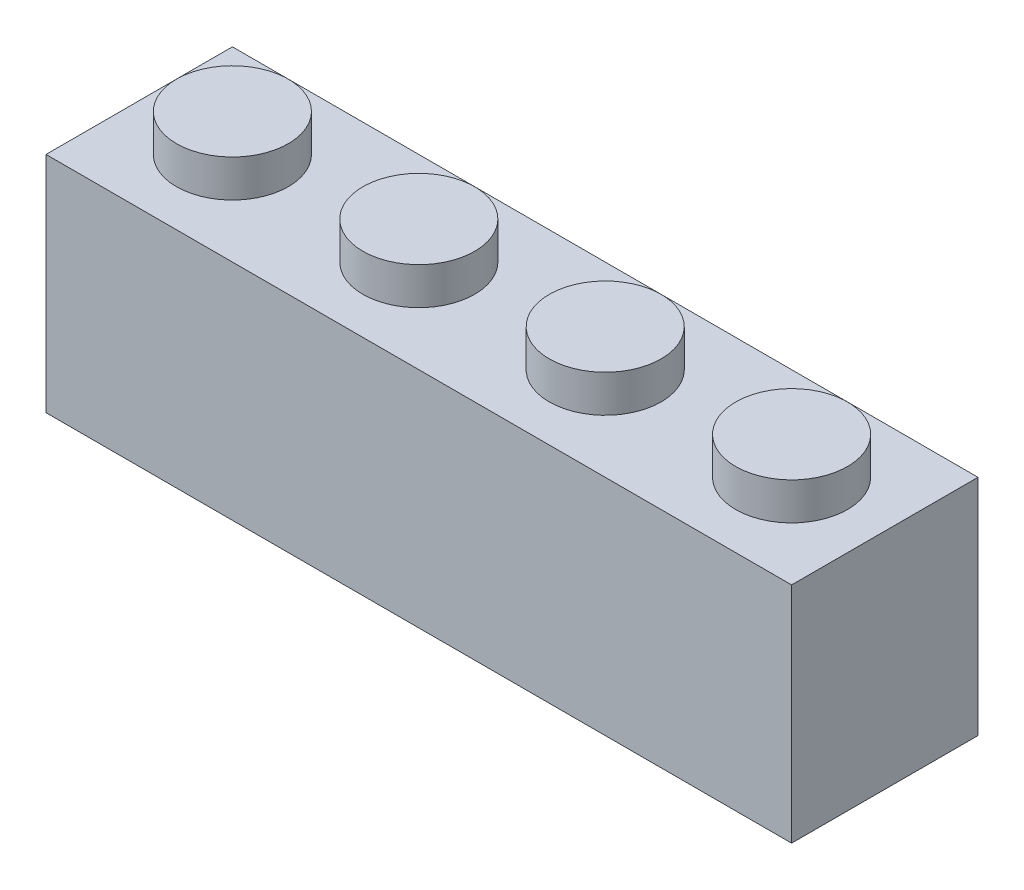
from build123d import *

# Parameters (mm, degrees)
SKETCH1_R             = 1.5
BOSS_EXTRUDE1_DEPTH   = 2
BOSS_EXTRUDE1_2_DEPTH = 2
BOSS_EXTRUDE1_3_DEPTH = 2
BOSS_EXTRUDE1_4_DEPTH = 2
SKETCH1_3_W           = 20
SKETCH1_3_H           = 5
BOSS_EXTRUDE2_DEPTH   = 1
SKETCH1_4_R           = 0.75
CUT_EXTRUDE1_DEPTH    = 1
SKETCH1_6_W           = 20
SKETCH1_6_H           = 5
SKETCH1_6_W_2         = 18
SKETCH1_6_H_2         = 3
SKETCH1_6_R           = 1
BOSS_EXTRUDE4_DEPTH   = 5


with BuildPart() as part:
    # Sketch1 → Boss-Extrude1 (new body)
    with BuildSketch(Plane(origin=(0, 0, 0), x_dir=(1, 0, 0), z_dir=(0, 1, 0))):
        with Locations((-7.5, 0)):
            Circle(SKETCH1_R)
    extrude(amount=BOSS_EXTRUDE1_DEPTH)



with BuildPart() as body_2:
    # Sketch1 → Boss-Extrude1 2 (new body)
    with BuildSketch(Plane(origin=(0, 0, 0), x_dir=(1, 0, 0), z_dir=(0, 1, 0))):
        with Locations((-2.5, 0)):
            Circle(SKETCH1_R)
    extrude(amount=BOSS_EXTRUDE1_2_DEPTH)


with BuildPart() as body_3:
    # Sketch1 → Boss-Extrude1 3 (new body)
    with BuildSketch(Plane(origin=(0, 0, 0), x_dir=(1, 0, 0), z_dir=(0, 1, 0))):
        with Locations((2.5, 0)):
            Circle(SKETCH1_R)
    extrude(amount=BOSS_EXTRUDE1_3_DEPTH)


with BuildPart() as body_4:
    # Sketch1 → Boss-Extrude1 4 (new body)
    with BuildSketch(Plane(origin=(0, 0, 0), x_dir=(1, 0, 0), z_dir=(0, 1, 0))):
        with Locations((7.5, 0)):
            Circle(SKETCH1_R)
    extrude(amount=BOSS_EXTRUDE1_4_DEPTH)


with BuildPart() as part_1:
    add(part.part)

    add(body_2.part)  # Boss-Extrude2 merges body 2

    add(body_3.part)  # Boss-Extrude2 merges body 3

    add(body_4.part)  # Boss-Extrude2 merges body 4
    # Sketch1_3 → Boss-Extrude2 (add)
    with BuildSketch(Plane(origin=(0, 0, 0), x_dir=(1, 0, 0), z_dir=(0, 1, 0))):
        Rectangle(SKETCH1_3_W, SKETCH1_3_H)
    extrude(amount=BOSS_EXTRUDE2_DEPTH)

    # Sketch1_4 → Cut-Extrude1 (cut)
    with BuildSketch(Plane(origin=(0, 0, 0), x_dir=(1, 0, 0), z_dir=(0, 1, 0))):
        with Locations((-7.5, 0)):
            Circle(SKETCH1_4_R)
        with Locations((-2.5, 0)):
            Circle(SKETCH1_4_R)
        with Locations((2.5, 0)):
            Circle(SKETCH1_4_R)
        with Locations((7.5, 0)):
            Circle(SKETCH1_4_R)
    extrude(amount=CUT_EXTRUDE1_DEPTH, mode=Mode.SUBTRACT)

    # Sketch1_6 → Boss-Extrude4 (add)
    # profile 1 of 4: a face of its own
    with BuildSketch(Plane(origin=(0, 0, 0), x_dir=(1, 0, 0), z_dir=(0, 1, 0))):
        Rectangle(SKETCH1_6_W, SKETCH1_6_H)
        Rectangle(SKETCH1_6_W_2, SKETCH1_6_H_2, mode=Mode.SUBTRACT)
    # profile 2 of 4: a face of its own
    with BuildSketch(Plane(origin=(0, 0, 0), x_dir=(1, 0, 0), z_dir=(0, 1, 0))):
        with Locations((5, 0)):
            Circle(SKETCH1_6_R)
    # profile 3 of 4: a face of its own
    with BuildSketch(Plane(origin=(0, 0, 0), x_dir=(1, 0, 0), z_dir=(0, 1, 0))):
        Circle(SKETCH1_6_R)
    # profile 4 of 4: a face of its own
    with BuildSketch(Plane(origin=(0, 0, 0), x_dir=(1, 0, 0), z_dir=(0, 1, 0))):
        with Locations((-5, 0)):
            Circle(SKETCH1_6_R)
    extrude(amount=-BOSS_EXTRUDE4_DEPTH)


solid = part_1.part
